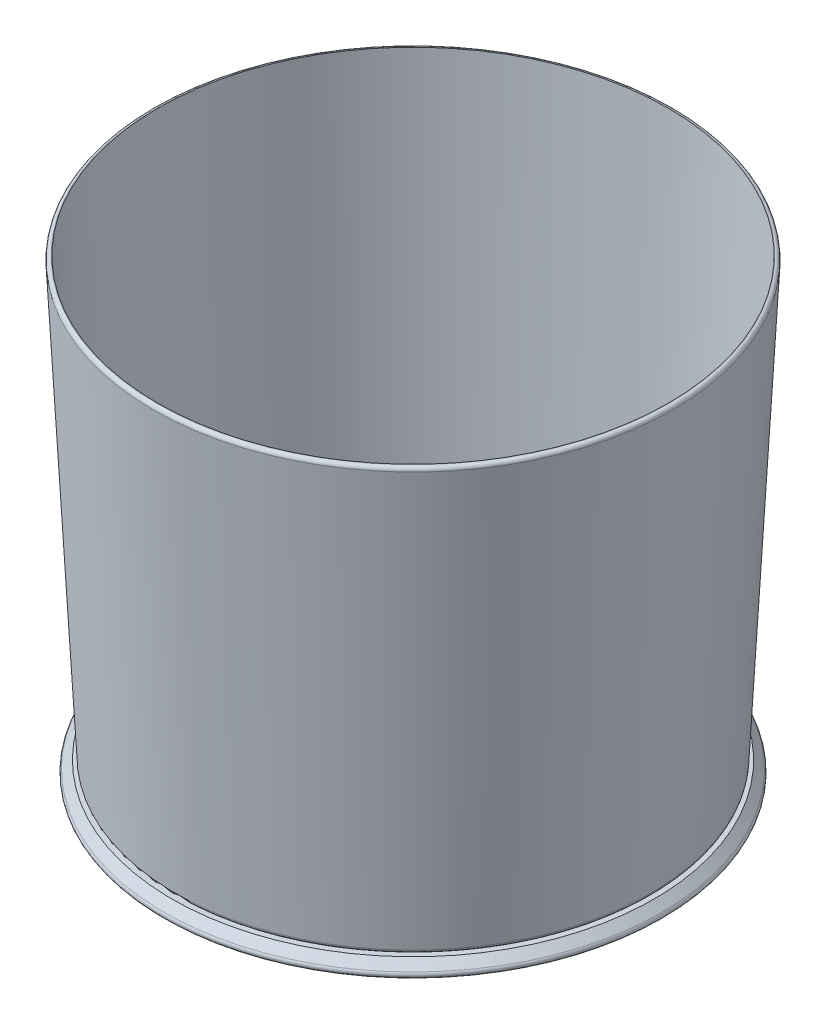
from build123d import *


with BuildPart() as part:
    # Sketch1 → Revolve1 (revolve)
    with BuildSketch(Plane.XY):
        with BuildLine():
            Line((180.862254067, -468.383325669), (171.360424036, -468.383325669))
            ThreePointArc((171.360424036, -468.383325669), (174.804519989, -467.007991593), (176.353902933, -463.638606894))
            Line((176.353902933, -463.638606894), (206.516426137, 126.361393106))
            ThreePointArc((206.516426137, 126.361393106), (205.147613164, 130.060770285), (201.52294724, 131.616674331))
            Line((201.52294724, 131.616674331), (200.860485156, 131.616674331))
            Line((200.860485156, 131.616674331), (170.983852863, -452.791099984))
            ThreePointArc((170.983852863, -452.791099984), (169.434469919, -456.160484683), (165.990373966, -457.535818758))
            Line((165.990373966, -457.535818758), (-149.139514844, -457.535818758))
            Line((-149.139514844, -457.535818758), (-149.139514844, -487.535818758))
            Line((-149.139514844, -487.535818758), (187.943679345, -487.535818758))
            ThreePointArc((187.943679345, -487.535818758), (192.563077007, -484.44923592), (191.479213251, -479.000284853))
            Line((191.479213251, -479.000284853), (180.862254067, -468.383325669))
        make_face()
    revolve(axis=Axis((-150.008312882, -212.837137396, 0), (0, -1, 0)))


solid = part.part
